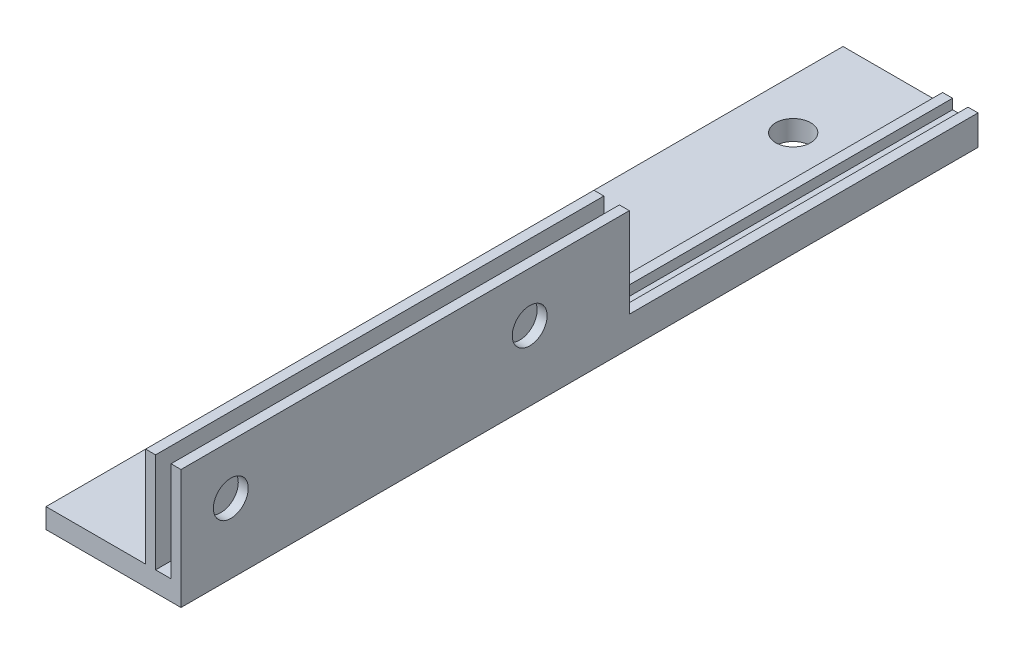
from build123d import *

# Parameters (mm, degrees)
BOSS_EXTRUDE1_DEPTH = 45
BOSS_EXTRUDE2_DEPTH = 35
SKETCH2_R           = 1.75
CUT_EXTRUDE1_DEPTH  = 4.55
CUT_EXTRUDE2_REACH  = 4
SKETCH3_R           = 1.75


with BuildPart() as part:
    # Sketch1 → Boss-Extrude1 (new body)
    with BuildSketch(Plane.XY):
        Polygon((0, 0), (0, 2), (10, 2), (10, 12), (11, 12), (11, 2), (12.55, 2), (12.55, 12), (13.55, 12), (13.55, 0), align=None)
    extrude(amount=BOSS_EXTRUDE1_DEPTH)

    # Sketch4 → Boss-Extrude2 (add)
    with BuildSketch(Plane.XY):
        Polygon((0, 2), (0, 0), (13.55, 0), (13.55, 3), (12.55, 3), (12.55, 2), (11, 2), (11, 3), (10, 3), (10, 2), align=None)
    extrude(amount=-BOSS_EXTRUDE2_DEPTH)

    # Sketch2 → Cut-Extrude1 (cut, through all)
    with BuildSketch(Plane.ZY.offset(-10)):
        with Locations((40, 7)):
            Circle(SKETCH2_R)
        with Locations((10, 7)):
            Circle(SKETCH2_R)
    extrude(amount=-CUT_EXTRUDE1_DEPTH, mode=Mode.SUBTRACT)

    # Sketch3 → Cut-Extrude2 (cut, up to next)
    with BuildSketch(Plane(origin=(0, 2, 0), x_dir=(1, 0, 0), z_dir=(0, 1, 0)), mode=Mode.PRIVATE) as cut_extrude2_sk1:
        with Locations((5, 25)):
            Circle(SKETCH3_R)
    cut_extrude2_tool1 = extrude(cut_extrude2_sk1.sketch, amount=-CUT_EXTRUDE2_REACH, mode=Mode.PRIVATE) & part.part
    add(cut_extrude2_tool1.solids().sort_by_distance((5, 2, -25))[0], mode=Mode.SUBTRACT)
    # Sketch3 → Cut-Extrude2 (cut, up to next)
    with BuildSketch(Plane(origin=(0, 2, 0), x_dir=(1, 0, 0), z_dir=(0, 1, 0)), mode=Mode.PRIVATE) as cut_extrude2_sk2:
        with Locations((5, -35)):
            Circle(SKETCH3_R)
    cut_extrude2_tool2 = extrude(cut_extrude2_sk2.sketch, amount=-CUT_EXTRUDE2_REACH, mode=Mode.PRIVATE) & part.part
    add(cut_extrude2_tool2.solids().sort_by_distance((5, 2, 35))[0], mode=Mode.SUBTRACT)


solid = part.part
